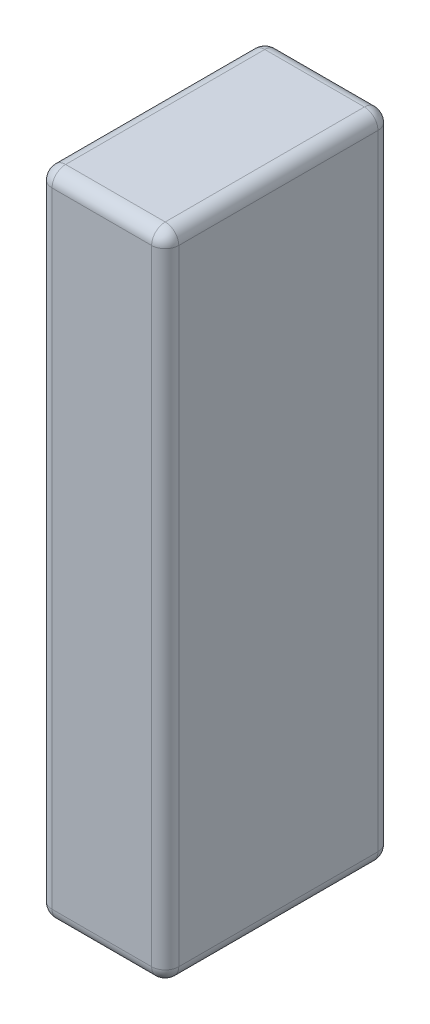
from build123d import *

# Parameters (mm, degrees)
SKETCH1_W           = 28
SKETCH1_H           = 50
BOSS_EXTRUDE1_DEPTH = 144
FILLET1_R           = 3


with BuildPart() as part:
    # Sketch1 → Boss-Extrude1 (new body)
    with BuildSketch(Plane(origin=(0, 0, 0), x_dir=(1, 0, 0), z_dir=(0, 1, 0))):
        with Locations((14, 25)):
            Rectangle(SKETCH1_W, SKETCH1_H)
    extrude(amount=BOSS_EXTRUDE1_DEPTH)

    # Fillet1
    fillet1_edges = [part.edges().sort_by_distance(p)[0] for p in [
        (28, 144, -25),
        (14, 144, -50),
        (0, 144, -25),
        (14, 0, -50),
        (28, 0, -25),
        (14, 0, 0),
        (0, 0, -25),
        (14, 144, 0),
        (0, 72, -50),
        (28, 72, -50),
        (28, 72, 0),
        (0, 72, 0),
    ]]
    fillet(fillet1_edges, radius=FILLET1_R)


solid = part.part
